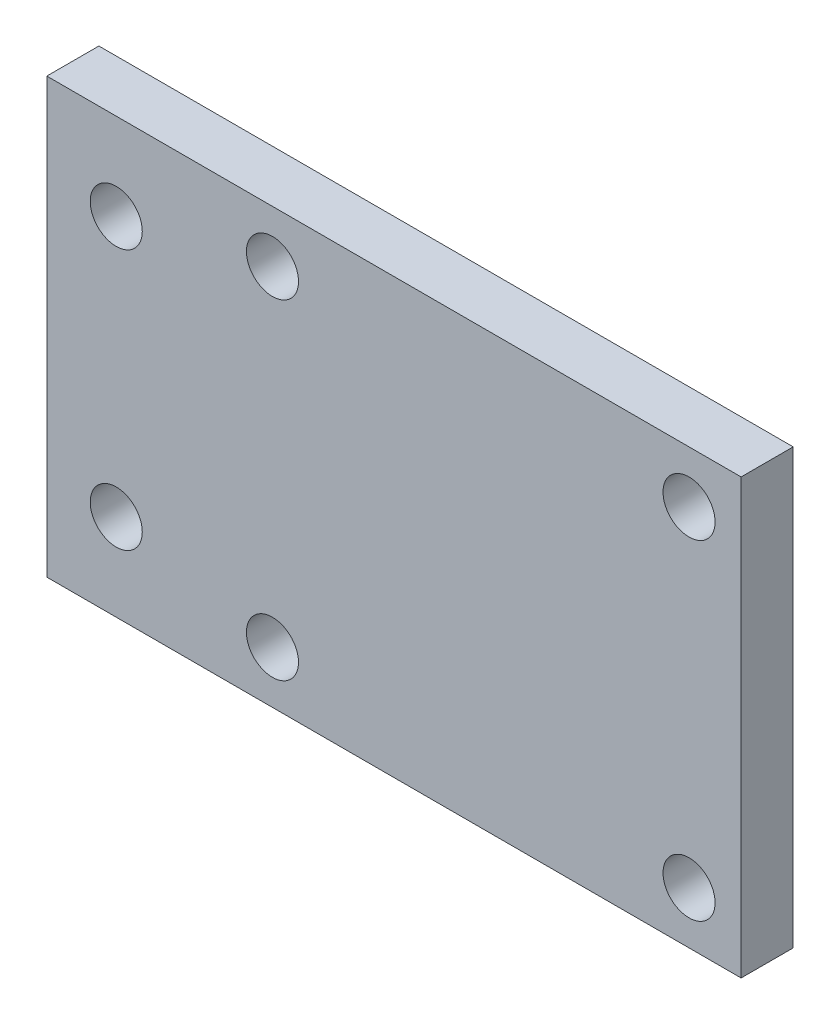
from build123d import *

# Parameters (mm, degrees)
SKETCH_1_W      = 40
SKETCH_1_H      = 25
SKETCH_1_R      = 1.5
EXTRUDE_1_DEPTH = 3


with BuildPart() as part:
    # 草图1 → 凸台-拉伸1 (new body)
    with BuildSketch(Plane.XY):
        Rectangle(SKETCH_1_W, SKETCH_1_H)
        with Locations((-7, 9.5)):
            Circle(SKETCH_1_R, mode=Mode.SUBTRACT)
        with Locations((17, 9.5)):
            Circle(SKETCH_1_R, mode=Mode.SUBTRACT)
        with Locations((-7, -9.5)):
            Circle(SKETCH_1_R, mode=Mode.SUBTRACT)
        with Locations((17, -9.5)):
            Circle(SKETCH_1_R, mode=Mode.SUBTRACT)
        with Locations((-16, 7.5)):
            Circle(SKETCH_1_R, mode=Mode.SUBTRACT)
        with Locations((-16, -7.5)):
            Circle(SKETCH_1_R, mode=Mode.SUBTRACT)
    extrude(amount=EXTRUDE_1_DEPTH)


solid = part.part
